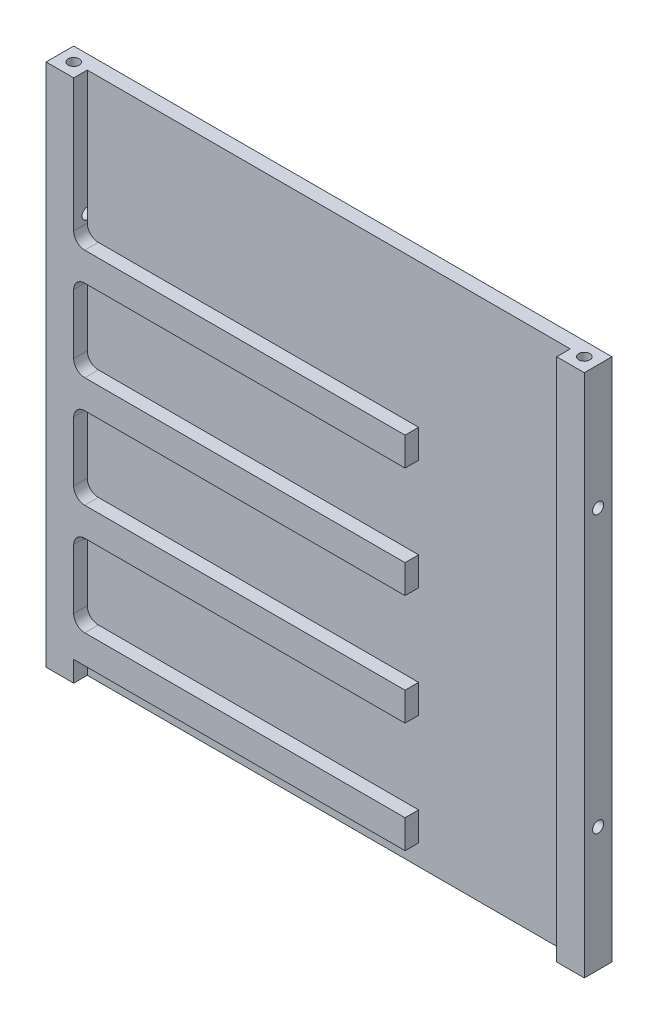
from build123d import *

# Parameters (mm, degrees)
SKETCH1_W           = 97.46
SKETCH1_H           = 97.46
BOSS_EXTRUDE1_DEPTH = 1.27
SKETCH3_W           = 5
SKETCH3_H           = 97.46
BOSS_EXTRUDE2_DEPTH = 3.73
SKETCH7_R           = 1
CUT_EXTRUDE2_DEPTH  = 5
SKETCH6_R           = 1
CUT_EXTRUDE3_DEPTH  = 5
SKETCH4_R           = 1
CUT_EXTRUDE4_DEPTH  = 5
SKETCH5_R           = 1
CUT_EXTRUDE5_DEPTH  = 5
FILLET1_R           = 2
SKETCH8_R           = 1
CUT_EXTRUDE6_DEPTH  = 10
SKETCH9_R           = 1
CUT_EXTRUDE7_DEPTH  = 10
BOSS_EXTRUDE3_DEPTH = 1.27
CUT_EXTRUDE8_DEPTH  = 1.27
CUT_EXTRUDE9_DEPTH  = 1.27


with BuildPart() as part:
    # Sketch1 → Boss-Extrude1 (new body)
    with BuildSketch(Plane.XY):
        with Locations((48.73, 48.73)):
            Rectangle(SKETCH1_W, SKETCH1_H)
    extrude(amount=BOSS_EXTRUDE1_DEPTH)

    # Sketch3 → Boss-Extrude2 (add)
    with BuildSketch(Plane.XY.offset(1.27)):
        Polygon((0, 0), (5, 0), (5, 5), (65, 5), (65, 10.172513956), (5, 10.172513956), (5, 25), (65, 25), (65, 30.172513956), (5, 30.172513956), (5, 45), (65, 45), (65, 50.172513956), (5, 50.172513956), (5, 65), (65, 65), (65, 70.172513956), (5, 70.172513956), (5, 97.46), (0, 97.46), align=None)
        with Locations((94.96, 48.73)):
            Rectangle(SKETCH3_W, SKETCH3_H)
    extrude(amount=BOSS_EXTRUDE2_DEPTH)

    # Sketch7 → Cut-Extrude2 (cut)
    with BuildSketch(Plane(origin=(0, 97.46, 0), x_dir=(-1, 0, 0), z_dir=(0, 1, 0))):
        with Locations((-2.5, 2.5)):
            Circle(SKETCH7_R)
    extrude(amount=-CUT_EXTRUDE2_DEPTH, mode=Mode.SUBTRACT)

    # Sketch6 → Cut-Extrude3 (cut)
    with BuildSketch(Plane(origin=(0, 97.46, 0), x_dir=(-1, 0, 0), z_dir=(0, 1, 0))):
        with Locations((-94.96, 2.5)):
            Circle(SKETCH6_R)
    extrude(amount=-CUT_EXTRUDE3_DEPTH, mode=Mode.SUBTRACT)

    # Sketch4 → Cut-Extrude4 (cut)
    with BuildSketch(Plane.XZ):
        with Locations((94.96, 2.5)):
            Circle(SKETCH4_R)
    extrude(amount=-CUT_EXTRUDE4_DEPTH, mode=Mode.SUBTRACT)

    # Sketch5 → Cut-Extrude5 (cut)
    with BuildSketch(Plane.XZ):
        with Locations((2.5, 2.5)):
            Circle(SKETCH5_R)
    extrude(amount=-CUT_EXTRUDE5_DEPTH, mode=Mode.SUBTRACT)

    # Fillet1
    fillet1_edges = [part.edges().sort_by_distance(p)[0] for p in [
        (5, 70.172513956, 3.135),
        (5, 50.172513956, 3.135),
        (5, 30.172513956, 3.135),
        (5, 10.172513956, 3.135),
        (5, 65, 3.135),
        (5, 45, 3.135),
        (5, 25, 3.135),
    ]]
    fillet(fillet1_edges, radius=FILLET1_R)

    # Sketch8 → Cut-Extrude6 (cut)
    with BuildSketch(Plane.ZY):
        with Locations((2.5, 23.73)):
            Circle(SKETCH8_R)
        with Locations((2.5, 73.73)):
            Circle(SKETCH8_R)
    extrude(amount=-CUT_EXTRUDE6_DEPTH, mode=Mode.SUBTRACT)

    # Sketch9 → Cut-Extrude7 (cut)
    with BuildSketch(Plane(origin=(97.46, 0, 0), x_dir=(0, 0, -1), z_dir=(1, 0, 0))):
        with Locations((-2.5, 73.73)):
            Circle(SKETCH9_R)
        with Locations((-2.5, 23.73)):
            Circle(SKETCH9_R)
    extrude(amount=-CUT_EXTRUDE7_DEPTH, mode=Mode.SUBTRACT)

    # Sketch3_5 → Boss-Extrude3 (add)
    with BuildSketch(Plane.XY.offset(1.27)):
        Polygon((65, 5), (5, 5), (5, 0), (92.46, 0), (92.46, 5), (92.46, 92.46), (92.46, 97.46), (5, 97.46), (5, 92.46), (5, 70.172513956), (65, 70.172513956), (65, 65), (5, 65), (5, 50.172513956), (65, 50.172513956), (65, 45), (5, 45), (5, 30.172513956), (65, 30.172513956), (65, 25), (5, 25), (5, 10.172513956), (65, 10.172513956), align=None)
    extrude(amount=BOSS_EXTRUDE3_DEPTH)

    # Sketch10 → Cut-Extrude8 (cut)
    with BuildSketch(Plane.XZ):
        Polygon((5, 5), (0, 5), (0, 0), (97.46, 0), (97.46, 5), (92.46, 5), (92.46, 2.54), (5, 2.54), align=None)
    extrude(amount=-CUT_EXTRUDE8_DEPTH, mode=Mode.SUBTRACT)

    # Sketch11 → Cut-Extrude9 (cut)
    with BuildSketch(Plane(origin=(0, 97.46, 0), x_dir=(1, 0, 0), z_dir=(0, 1, 0))):
        Polygon((92.46, -2.54), (92.46, -5), (97.46, -5), (97.46, 0), (0, 0), (0, -5), (5, -5), (5, -2.54), align=None)
    extrude(amount=-CUT_EXTRUDE9_DEPTH, mode=Mode.SUBTRACT)


solid = part.part
